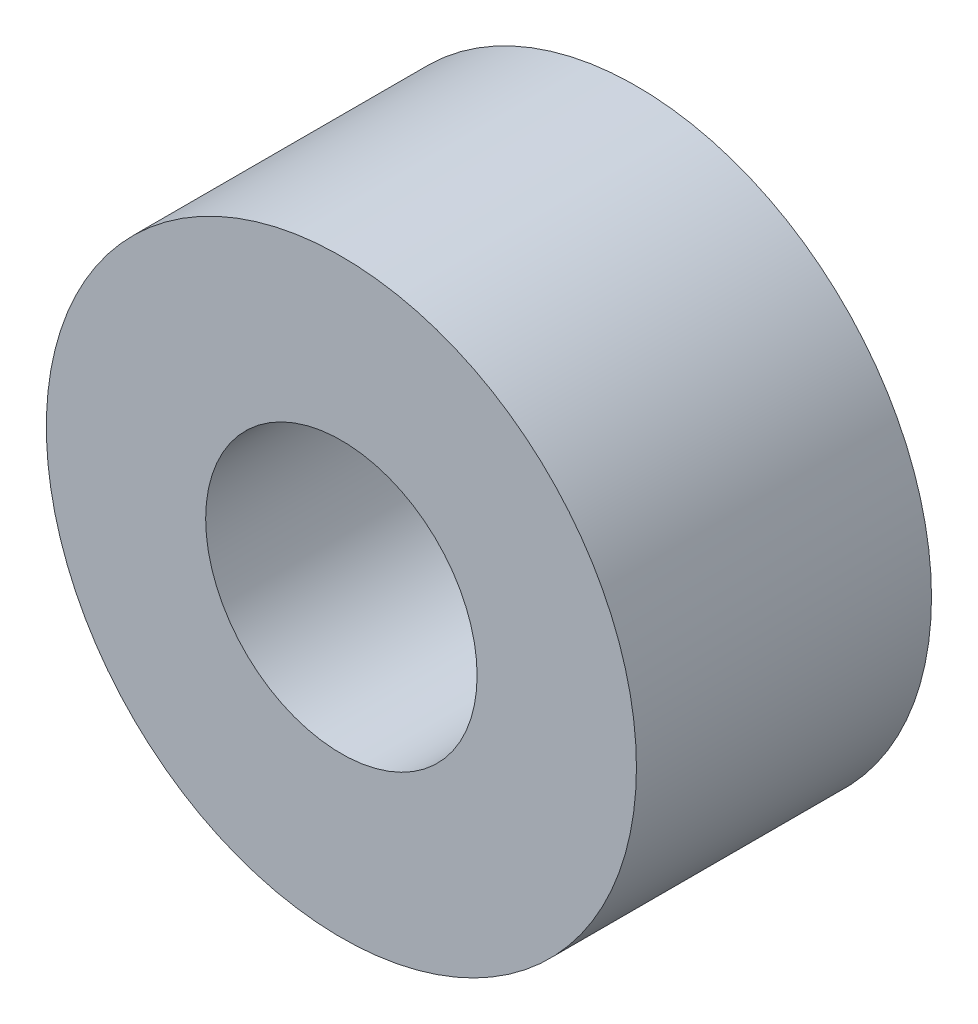
from build123d import *

# Parameters (mm, degrees)
SKETCH1_R      = 3.175
SKETCH1_R_2    = 1.4605
EXTRUDE1_DEPTH = 1.5875


with BuildPart() as part:
    # Sketch1 → Extrude1 (new body, symmetric)
    with BuildSketch(Plane.XY):
        Circle(SKETCH1_R)
        Circle(SKETCH1_R_2, mode=Mode.SUBTRACT)
    extrude(amount=EXTRUDE1_DEPTH, both=True)


solid = part.part
